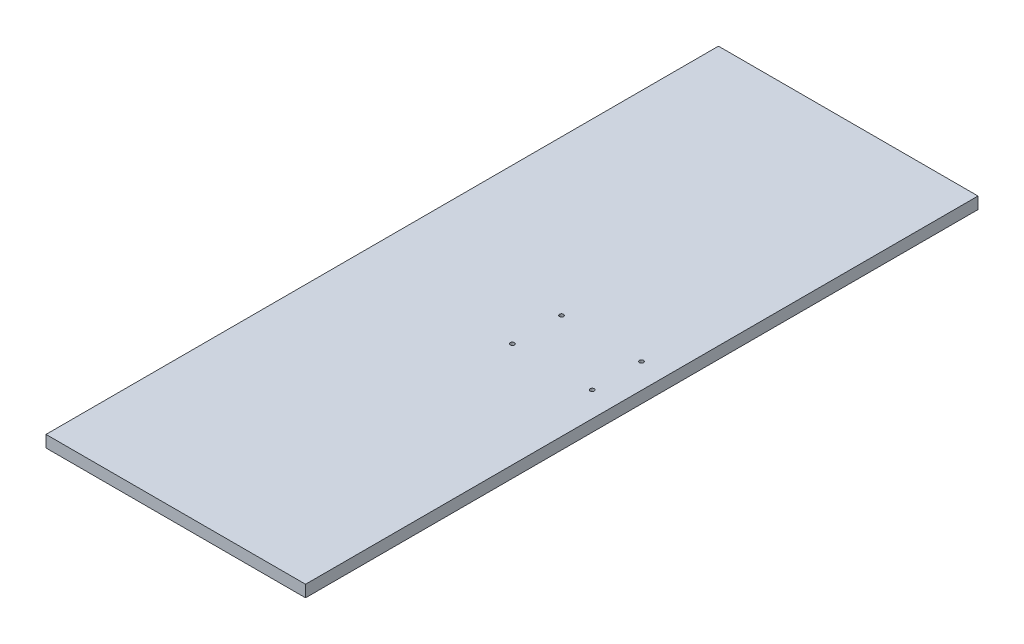
from build123d import *

# Parameters (mm, degrees)
SKETCH1_W           = 220
SKETCH1_H           = 570
BOSS_EXTRUDE1_DEPTH = 10
SKETCH2_R           = 1.75
CUT_EXTRUDE1_DEPTH  = 10


with BuildPart() as part:
    # Sketch1 → Boss-Extrude1 (new body)
    with BuildSketch(Plane(origin=(0, 0, 0), x_dir=(1, 0, 0), z_dir=(0, 1, 0))):
        Rectangle(SKETCH1_W, SKETCH1_H)
    extrude(amount=BOSS_EXTRUDE1_DEPTH)

    # Sketch2 → Cut-Extrude1 (cut)
    with BuildSketch(Plane(origin=(0, 10, 0), x_dir=(1, 0, 0), z_dir=(0, 1, 0))):
        with Locations((21.16, 20.84)):
            Circle(SKETCH2_R)
        with Locations((88.84, 20.84)):
            Circle(SKETCH2_R)
        with Locations((21.16, -20.84)):
            Circle(SKETCH2_R)
        with Locations((88.84, -20.84)):
            Circle(SKETCH2_R)
    extrude(amount=-CUT_EXTRUDE1_DEPTH, mode=Mode.SUBTRACT)


solid = part.part
